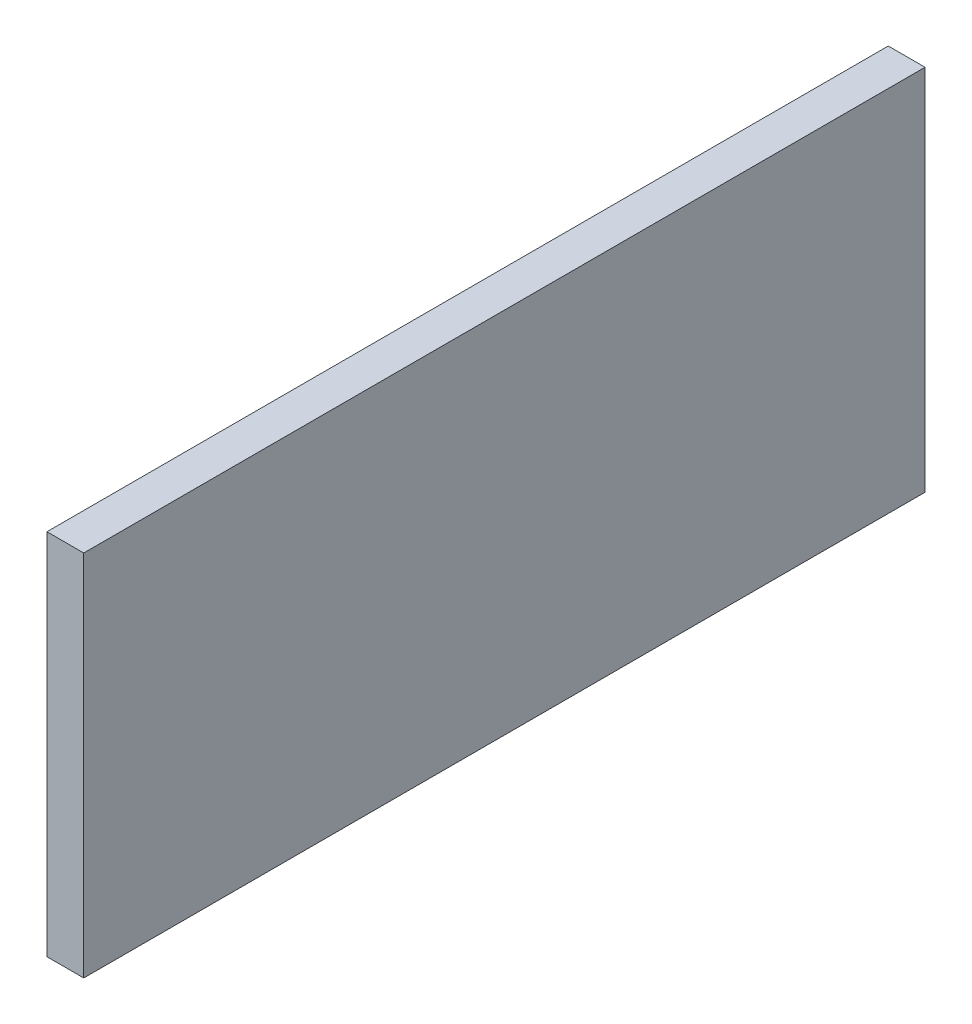
from build123d import *

# Parameters (mm, degrees)
SKETCH1_W           = 160
SKETCH1_H           = 70
BOSS_EXTRUDE1_DEPTH = 7


with BuildPart() as part:
    # Sketch1 → Boss-Extrude1 (new body)
    with BuildSketch(Plane(origin=(0, 0, 0), x_dir=(0, 0, -1), z_dir=(1, 0, 0))):
        Rectangle(SKETCH1_W, SKETCH1_H)
    extrude(amount=BOSS_EXTRUDE1_DEPTH)


solid = part.part
